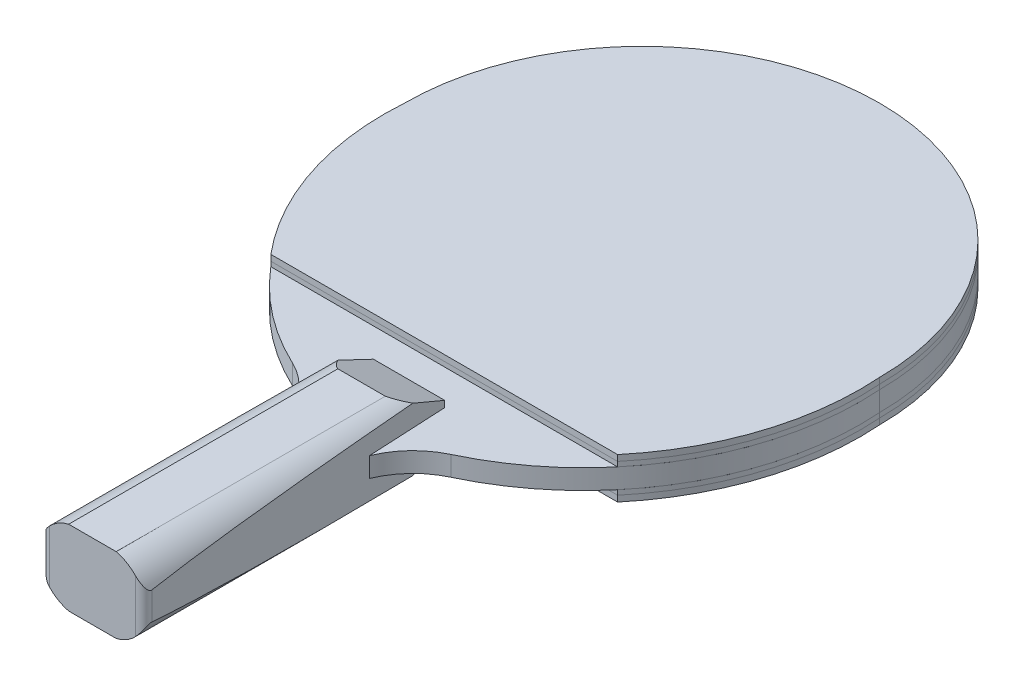
from build123d import *

# Parameters (mm, degrees)
BOSS_EXTRUDE1_DEPTH = 6.35
BOSS_EXTRUDE2_DEPTH = 1.524
BOSS_EXTRUDE4_DEPTH = 1.905
BOSS_EXTRUDE5_DEPTH = 1.524
BOSS_EXTRUDE6_DEPTH = 1.905
BOSS_EXTRUDE7_DEPTH = 8.89
CUT_EXTRUDE1_DEPTH  = 101.6
CUT_EXTRUDE2_DEPTH  = 25.4


with BuildPart() as part:
    # Sketch2 → Boss-Extrude1 (new body)
    with BuildSketch(Plane(origin=(0, 0, 0), x_dir=(1, 0, 0), z_dir=(0, 1, 0))):
        with BuildLine():
            Line((-12.7, -100.170905775), (-16.376657923, -173.704064228))
            ThreePointArc((-16.376657923, -173.704064228), (-15.680177156, -175.581537443), (-13.839826982, -176.370905775))
            Line((-13.839826982, -176.370905775), (13.839826982, -176.370905775))
            ThreePointArc((13.839826982, -176.370905775), (15.680177156, -175.581537443), (16.376657923, -173.704064228))
            Line((16.376657923, -173.704064228), (12.7, -100.170905775))
            ThreePointArc((12.7, -100.170905775), (17.790636658, -92.280726172), (25.4, -86.779171366))
            ThreePointArc((25.4, -86.779171366), (64.24812298, -51.26203522), (76.2, 0))
            ThreePointArc((76.2, 0), (0, 76.2), (-76.2, 0))
            ThreePointArc((-76.2, 0), (-64.24812298, -51.26203522), (-25.4, -86.779171366))
            ThreePointArc((-25.4, -86.779171366), (-17.790636658, -92.280726172), (-12.7, -100.170905775))
        make_face()
    extrude(amount=BOSS_EXTRUDE1_DEPTH)

    # Sketch7 → Boss-Extrude7 (add)
    with BuildSketch(Plane(origin=(0, 6.35, 0), x_dir=(1, 0, 0), z_dir=(0, 1, 0))):
        with BuildLine():
            Line((-11.43, -74.770905775), (-16.376657923, -173.704064228))
            ThreePointArc((-16.376657923, -173.704064228), (-15.680177156, -175.581537443), (-13.839826982, -176.370905775))
            Line((-13.839826982, -176.370905775), (13.839826982, -176.370905775))
            ThreePointArc((13.839826982, -176.370905775), (15.680177156, -175.581537443), (16.376657923, -173.704064228))
            Line((16.376657923, -173.704064228), (11.43, -74.770905775))
            Line((11.43, -74.770905775), (-11.43, -74.770905775))
        make_face()
    boss_extrude7 = extrude(amount=BOSS_EXTRUDE7_DEPTH)

    # Sketch8 → Cut-Extrude1 (cut)
    with BuildSketch(Plane.XY.offset(176.370905775)):
        with BuildLine():
            Line((-13.839826982, 15.24), (-7.62, 15.24))
            ThreePointArc((-7.62, 15.24), (-12.921650252, 12.489613458), (-16.379826982, 7.62))
            Line((-16.379826982, 7.62), (-16.379826982, 15.24))
            Line((-16.379826982, 15.24), (-13.839826982, 15.24))
        make_face()
        with BuildLine():
            Line((16.379826982, 15.24), (13.839826982, 15.24))
            Line((13.839826982, 15.24), (7.62, 15.24))
            ThreePointArc((7.62, 15.24), (12.921650252, 12.489613458), (16.379826982, 7.62))
            Line((16.379826982, 7.62), (16.379826982, 15.24))
        make_face()
    cut_extrude1 = extrude(amount=-CUT_EXTRUDE1_DEPTH, mode=Mode.SUBTRACT)

    # Sketch9 → Cut-Extrude2 (cut, symmetric)
    with BuildSketch(Plane(origin=(0, 0, -0.19192658), x_dir=(0, 0, -1), z_dir=(1, 0, 0))):
        Polygon((-74.962832355, 8.382), (-90.202832355, 15.24), (-74.962832355, 15.24), align=None)
    cut_extrude2 = extrude(amount=CUT_EXTRUDE2_DEPTH, both=True, mode=Mode.SUBTRACT)

    # Mirror8: Boss-Extrude7, Cut-Extrude1, Cut-Extrude2 across plane
    add(boss_extrude7.mirror(Plane.ZX.offset(3.175)))
    add(cut_extrude1.mirror(Plane.ZX.offset(3.175)), mode=Mode.SUBTRACT)
    add(cut_extrude2.mirror(Plane.ZX.offset(3.175)), mode=Mode.SUBTRACT)


with BuildPart() as body_2:
    # Sketch3 → Boss-Extrude2 (new body)
    with BuildSketch(Plane(origin=(0, 6.35, 0), x_dir=(1, 0, 0), z_dir=(0, 1, 0))):
        with BuildLine():
            Line((-55.623239344, -63.5), (55.623239344, -63.5))
            ThreePointArc((55.623239344, -63.5), (72.09775167, -33.754575709), (76.2, 0))
            ThreePointArc((76.2, 0), (0, 76.2), (-76.2, 0))
            ThreePointArc((-76.2, 0), (-72.09775167, -33.754575709), (-55.623239344, -63.5))
        make_face()
    extrude(amount=BOSS_EXTRUDE2_DEPTH)


with BuildPart() as body_3:
    # Sketch4 → Boss-Extrude4 (new body)
    with BuildSketch(Plane(origin=(0, 7.874, 0), x_dir=(1, 0, 0), z_dir=(0, 1, 0))):
        with BuildLine():
            Line((-55.623239344, -63.5), (55.623239344, -63.5))
            ThreePointArc((55.623239344, -63.5), (72.09775167, -33.754575709), (76.2, 0))
            ThreePointArc((76.2, 0), (0, 76.2), (-76.2, 0))
            ThreePointArc((-76.2, 0), (-72.09775167, -33.754575709), (-55.623239344, -63.5))
        make_face()
    extrude(amount=BOSS_EXTRUDE4_DEPTH)


with BuildPart() as body_4:
    # Sketch5 → Boss-Extrude5 (new body)
    with BuildSketch(Plane.XZ):
        with BuildLine():
            Line((55.623239344, 63.5), (-55.623239344, 63.5))
            ThreePointArc((-55.623239344, 63.5), (-72.09775167, 33.754575709), (-76.2, 0))
            ThreePointArc((-76.2, 0), (0, -76.2), (76.2, 0))
            ThreePointArc((76.2, 0), (72.09775167, 33.754575709), (55.623239344, 63.5))
        make_face()
    extrude(amount=BOSS_EXTRUDE5_DEPTH)


with BuildPart() as body_5:
    # Sketch6 → Boss-Extrude6 (new body)
    with BuildSketch(Plane.XZ.offset(1.524)):
        with BuildLine():
            Line((55.623239344, 63.5), (-55.623239344, 63.5))
            ThreePointArc((-55.623239344, 63.5), (-72.09775167, 33.754575709), (-76.2, 0))
            ThreePointArc((-76.2, 0), (0, -76.2), (76.2, 0))
            ThreePointArc((76.2, 0), (72.09775167, 33.754575709), (55.623239344, 63.5))
        make_face()
    extrude(amount=BOSS_EXTRUDE6_DEPTH)


solid = Compound([part.part, body_2.part, body_3.part, body_4.part, body_5.part])
